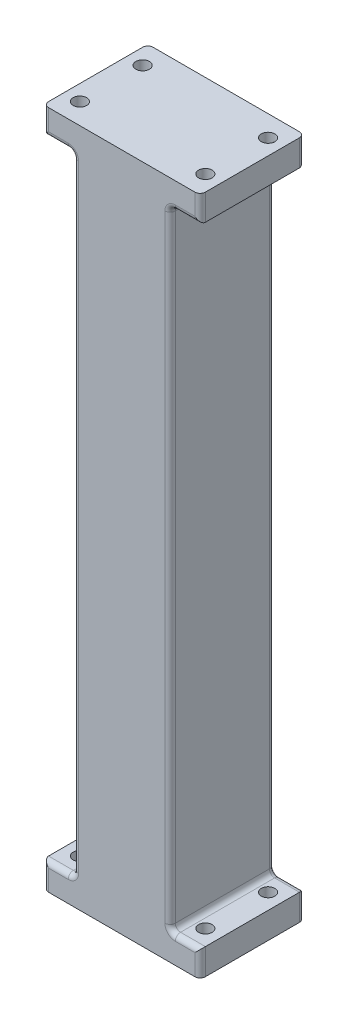
from build123d import *

# Parameters (mm, degrees)
SKETCH1_W           = 30
SKETCH1_H           = 20
SKETCH1_R           = 1.3
BOSS_EXTRUDE1_DEPTH = 5
SKETCH2_W           = 18.5
SKETCH2_H           = 20
BOSS_EXTRUDE2_DEPTH = 120
FILLET1_R           = 1


with BuildPart() as part:
    # Sketch1 → Boss-Extrude1 (new body)
    with BuildSketch(Plane(origin=(0, 0, 0), x_dir=(1, 0, 0), z_dir=(0, 1, 0))):
        Rectangle(SKETCH1_W, SKETCH1_H)
        with Locations((-12, 6)):
            Circle(SKETCH1_R, mode=Mode.SUBTRACT)
        with Locations((12, 6)):
            Circle(SKETCH1_R, mode=Mode.SUBTRACT)
        with Locations((12, -6)):
            Circle(SKETCH1_R, mode=Mode.SUBTRACT)
        with Locations((-12, -6)):
            Circle(SKETCH1_R, mode=Mode.SUBTRACT)
    boss_extrude1 = extrude(amount=BOSS_EXTRUDE1_DEPTH)

    # Sketch2 → Boss-Extrude2 (add)
    with BuildSketch(Plane(origin=(0, 5, 0), x_dir=(1, 0, 0), z_dir=(0, 1, 0))):
        Rectangle(SKETCH2_W, SKETCH2_H)
    extrude(amount=BOSS_EXTRUDE2_DEPTH)

    # Mirror1: Boss-Extrude1 across plane
    add(boss_extrude1.mirror(Plane.ZX.offset(65)))

    # Fillet1
    fillet1_edges = [part.edges().sort_by_distance(p)[0] for p in [
        (12.125, 5, 10),
        (12.125, 5, -10),
        (-12.125, 5, -10),
        (-12.125, 5, 10),
        (-12.125, 125, -10),
        (-12.125, 125, 10),
        (12.125, 125, 10),
        (12.125, 125, -10),
        (9.25, 5, 0),
        (-9.25, 5, 0),
        (-9.25, 125, 0),
        (9.25, 125, 0),
        (9.25, 65, -10),
        (9.25, 65, 10),
        (-9.25, 65, 10),
        (-9.25, 65, -10),
        (-15, 2.5, -10),
        (-15, 2.5, 10),
        (15, 2.5, 10),
        (15, 2.5, -10),
        (15, 127.5, 10),
        (15, 127.5, -10),
        (-15, 127.5, -10),
        (-15, 127.5, 10),
    ]]
    fillet(fillet1_edges, radius=FILLET1_R)


solid = part.part
